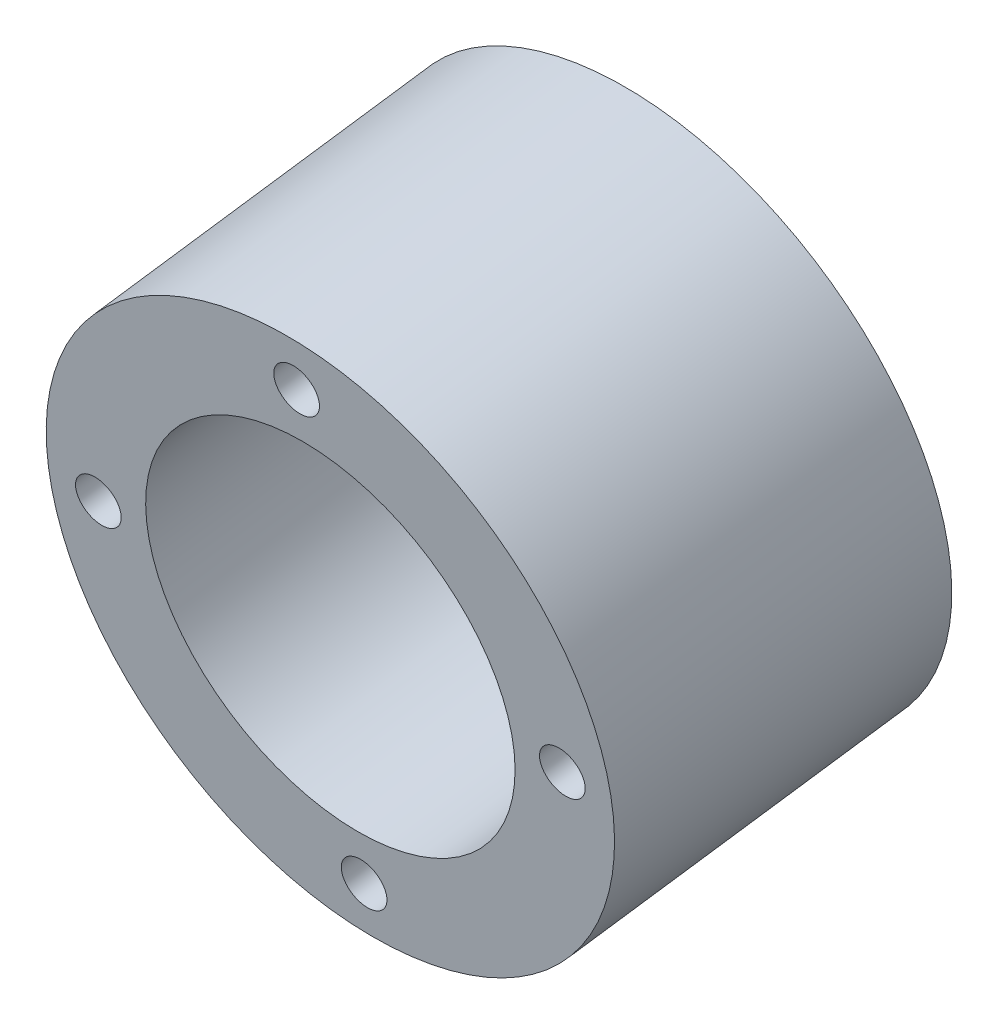
from build123d import *

# Parameters (mm, degrees)
SKETCH1_R                   = 31.75
SKETCH1_R_2                 = 20.6375
BOSS_EXTRUDE1_DEPTH         = 19.05
F_1_4_20_TAPPED_HOLE1_D     = 5.1054
F_1_4_20_TAPPED_HOLE1_DEPTH = 38.1


with BuildPart() as part:
    # Sketch1 → Boss-Extrude1 (new body, symmetric)
    with BuildSketch(Plane(origin=(0, 577.92693102, 1367.654430732), x_dir=(0.999987453, -0.000687148, 0.004962002), z_dir=(-0.005009211, -0.144685018, 0.989465084))):
        Circle(SKETCH1_R)
        Circle(SKETCH1_R_2, mode=Mode.SUBTRACT)
    extrude(amount=BOSS_EXTRUDE1_DEPTH, both=True)

    # 1/4-20 Tapped Hole1
    with Locations(Plane(origin=(-6.264413672, -180.940036548, 1237.404194636), x_dir=(-0.999987401, 0.001044934, -0.004909685), z_dir=(0.005009211, 0.144685018, -0.989465084))):
        with Locations((-32.304604681, 769.73877208), (-6.101384965, 795.923048939), (20.082891894, 769.719829223), (-6.120327822, 743.535552364)):
            Hole(F_1_4_20_TAPPED_HOLE1_D / 2, depth=F_1_4_20_TAPPED_HOLE1_DEPTH)


solid = part.part
